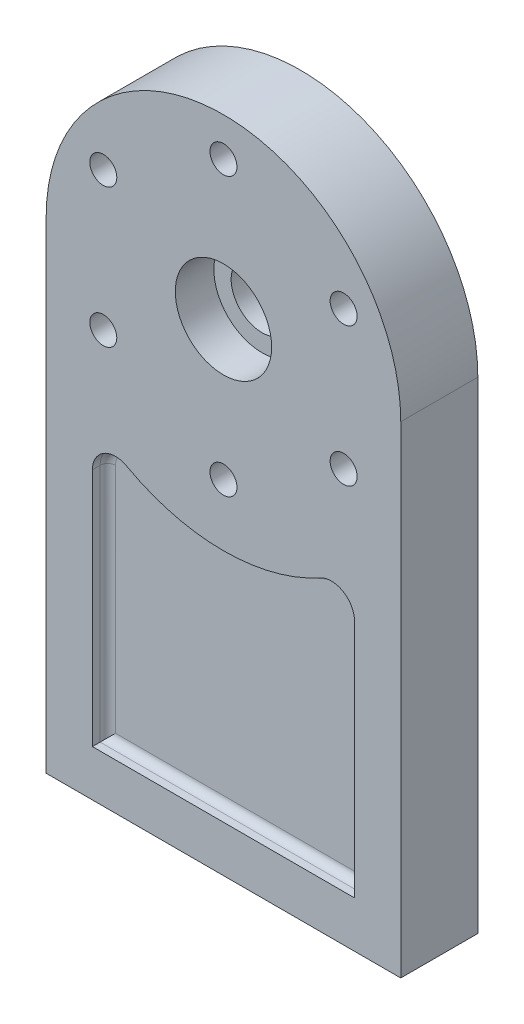
from build123d import *

# Parameters (mm, degrees)
SKETCH1_R                         = 8
BOSS_EXTRUDE1_DEPTH               = 10
SKETCH2_R                         = 12.5
CUT_EXTRUDE1_DEPTH                = 10
SKETCH3_R                         = 3.5
CUT_EXTRUDE2_DEPTH                = 21
SKETCH4_R                         = 6
CUT_EXTRUDE3_DEPTH                = 6
CIRPATTERN1_COUNT                 = 6
TAP_DRILL_FOR_M10X1_25_TAP2_D     = 8.8
TAP_DRILL_FOR_M10X1_25_TAP2_DEPTH = 24
TAP_DRILL_FOR_M10X1_25_TAP2_TIP   = 2.643786724
CUT_EXTRUDE4_DEPTH                = 4
FILLET1_R                         = 2
FILLET1_OF_MIRROR1_R              = 2


with BuildPart() as part:
    # Sketch1 → Boss-Extrude1 (new body, symmetric)
    with BuildSketch(Plane.XY):
        with BuildLine():
            Line((46, 125), (46, 0))
            Line((46, 0), (-46, 0))
            Line((-46, 0), (-46, 125))
            ThreePointArc((-46, 125), (0, 171), (46, 125))
        make_face()
        with Locations((0, 125)):
            Circle(SKETCH1_R, mode=Mode.SUBTRACT)
    extrude(amount=BOSS_EXTRUDE1_DEPTH, both=True)

    # Sketch2 → Cut-Extrude1 (cut)
    with BuildSketch(Plane.XY.offset(10)):
        with Locations((0, 125)):
            Circle(SKETCH2_R)
    extrude(amount=-CUT_EXTRUDE1_DEPTH, mode=Mode.SUBTRACT)

    # Sketch3 → Cut-Extrude2 (cut, through all)
    with BuildSketch(Plane.XY.offset(10)):
        with Locations((0, 161)):
            Circle(SKETCH3_R)
    cut_extrude2 = extrude(amount=-CUT_EXTRUDE2_DEPTH, mode=Mode.SUBTRACT)

    # Sketch4 → Cut-Extrude3 (cut)
    with BuildSketch(Plane(origin=(0, 0, -10), x_dir=(-1, 0, 0), z_dir=(0, 0, -1))):
        with Locations((0, 161)):
            Circle(SKETCH4_R)
    cut_extrude3 = extrude(amount=-CUT_EXTRUDE3_DEPTH, mode=Mode.SUBTRACT)

    # CirPattern1: Cut-Extrude2, Cut-Extrude3 ×6 about axis
    cirpattern1_axis = Axis((0, 125, 0), (0, 0, 1))
    for i in range(1, CIRPATTERN1_COUNT):
        add(cut_extrude2.rotate(cirpattern1_axis, i * 360 / CIRPATTERN1_COUNT), mode=Mode.SUBTRACT)
        add(cut_extrude3.rotate(cirpattern1_axis, i * 360 / CIRPATTERN1_COUNT), mode=Mode.SUBTRACT)

    # Tap Drill for M10x1.25 Tap2
    with Locations(Plane(origin=(0, 0, 0), x_dir=(-1, 0, 0), z_dir=(0, -1, 0))):
        with Locations((30, 0), (-30, 0)):
            Hole(TAP_DRILL_FOR_M10X1_25_TAP2_D / 2, depth=TAP_DRILL_FOR_M10X1_25_TAP2_DEPTH)
            with Locations((0, 0, -(TAP_DRILL_FOR_M10X1_25_TAP2_DEPTH + TAP_DRILL_FOR_M10X1_25_TAP2_TIP / 2))):  # 118° drill point
                Cone(0, TAP_DRILL_FOR_M10X1_25_TAP2_D / 2, TAP_DRILL_FOR_M10X1_25_TAP2_TIP, mode=Mode.SUBTRACT)

    # Sketch11 → Cut-Extrude4 (cut)
    with BuildSketch(Plane.XY.offset(10)):
        with BuildLine():
            Line((-34, 74.206299603), (-34, 12))
            Line((-34, 12), (34, 12))
            Line((34, 12), (34, 74.206299603))
            ThreePointArc((34, 74.206299603), (31.051285766, 79.372502771), (25.103448276, 79.460820334))
            ThreePointArc((25.103448276, 79.460820334), (0, 73), (-25.103448276, 79.460820334))
            ThreePointArc((-25.103448276, 79.460820334), (-31.051285766, 79.372502771), (-34, 74.206299603))
        make_face()
    cut_extrude4 = extrude(amount=-CUT_EXTRUDE4_DEPTH, mode=Mode.SUBTRACT)

    # Fillet1
    fillet1_edges = [part.edges().sort_by_distance(p)[0] for p in [
        (31.051285766, 79.372502771, 6),
        (34, 43.103149802, 6),
        (0, 12, 6),
        (-34, 43.103149802, 6),
        (-31.051285766, 79.372502771, 6),
        (0, 73, 6),
    ]]
    fillet(fillet1_edges, radius=FILLET1_R)

    # Mirror1: Cut-Extrude4 across plane
    add(cut_extrude4.mirror(Plane.XY), mode=Mode.SUBTRACT)

    # Fillet1 of Mirror1
    fillet1_of_mirror1_edges = [part.edges().sort_by_distance(p)[0] for p in [
        (31.051285766, 79.372502771, -6),
        (34, 43.103149802, -6),
        (0, 12, -6),
        (-34, 43.103149802, -6),
        (-31.051285766, 79.372502771, -6),
        (0, 73, -6),
    ]]
    fillet(fillet1_of_mirror1_edges, radius=FILLET1_OF_MIRROR1_R)


solid = part.part
